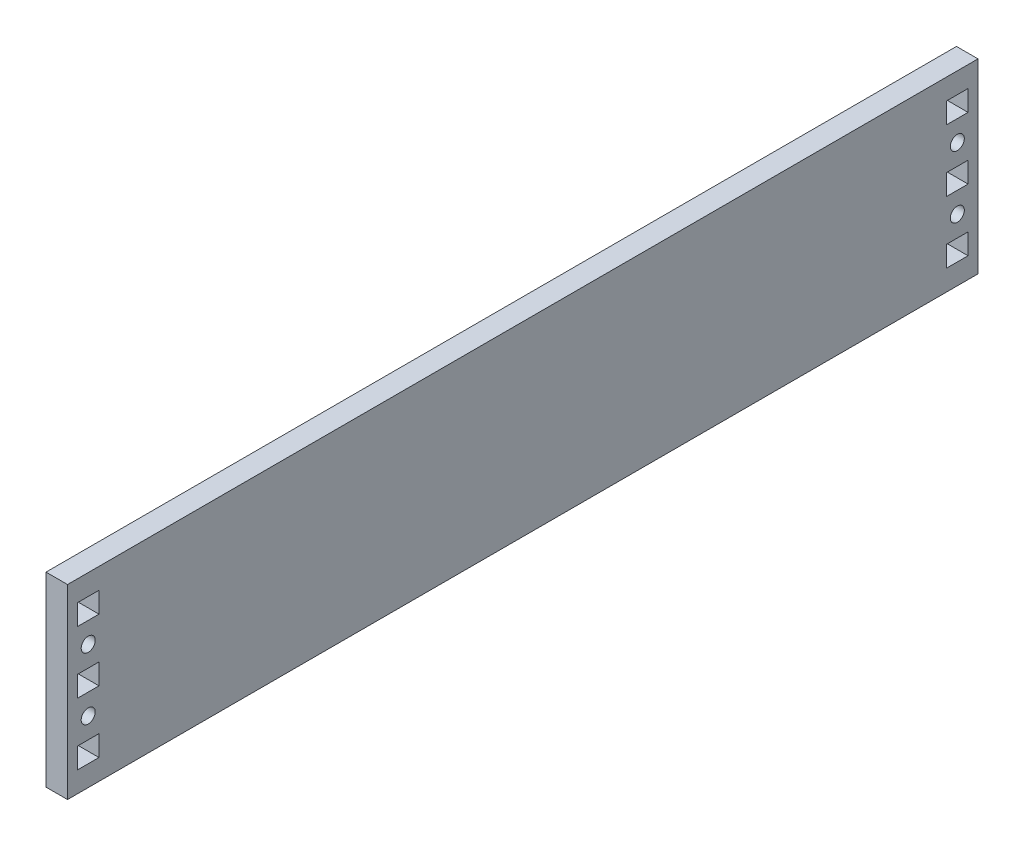
from build123d import *

# Parameters (mm, degrees)
SKETCH1_W           = 279.4
SKETCH1_H           = 57.15
SKETCH1_R           = 2.15265
SKETCH1_W_2         = 6.604
SKETCH1_H_2         = 6.35
BOSS_EXTRUDE1_DEPTH = 6.604


with BuildPart() as part:
    # Sketch1 → Boss-Extrude1 (new body)
    with BuildSketch(Plane(origin=(0, 0, 0), x_dir=(0, 0, -1), z_dir=(1, 0, 0))):
        Rectangle(SKETCH1_W, SKETCH1_H)
        with Locations((-133.35, 9.525)):
            Circle(SKETCH1_R, mode=Mode.SUBTRACT)
        with Locations((-133.35, -9.525)):
            Circle(SKETCH1_R, mode=Mode.SUBTRACT)
        with Locations((133.35, 9.525)):
            Circle(SKETCH1_R, mode=Mode.SUBTRACT)
        with Locations((133.35, -9.525)):
            Circle(SKETCH1_R, mode=Mode.SUBTRACT)
        with Locations((-133.35, 0)):
            Rectangle(SKETCH1_W_2, SKETCH1_H_2, mode=Mode.SUBTRACT)
        with Locations((-133.35, 19.05)):
            Rectangle(SKETCH1_W_2, SKETCH1_H_2, mode=Mode.SUBTRACT)
        with Locations((-133.35, -19.05)):
            Rectangle(SKETCH1_W_2, SKETCH1_H_2, mode=Mode.SUBTRACT)
        with Locations((133.35, 0)):
            Rectangle(SKETCH1_W_2, SKETCH1_H_2, mode=Mode.SUBTRACT)
        with Locations((133.35, 19.05)):
            Rectangle(SKETCH1_W_2, SKETCH1_H_2, mode=Mode.SUBTRACT)
        with Locations((133.35, -19.05)):
            Rectangle(SKETCH1_W_2, SKETCH1_H_2, mode=Mode.SUBTRACT)
    extrude(amount=BOSS_EXTRUDE1_DEPTH)


solid = part.part
